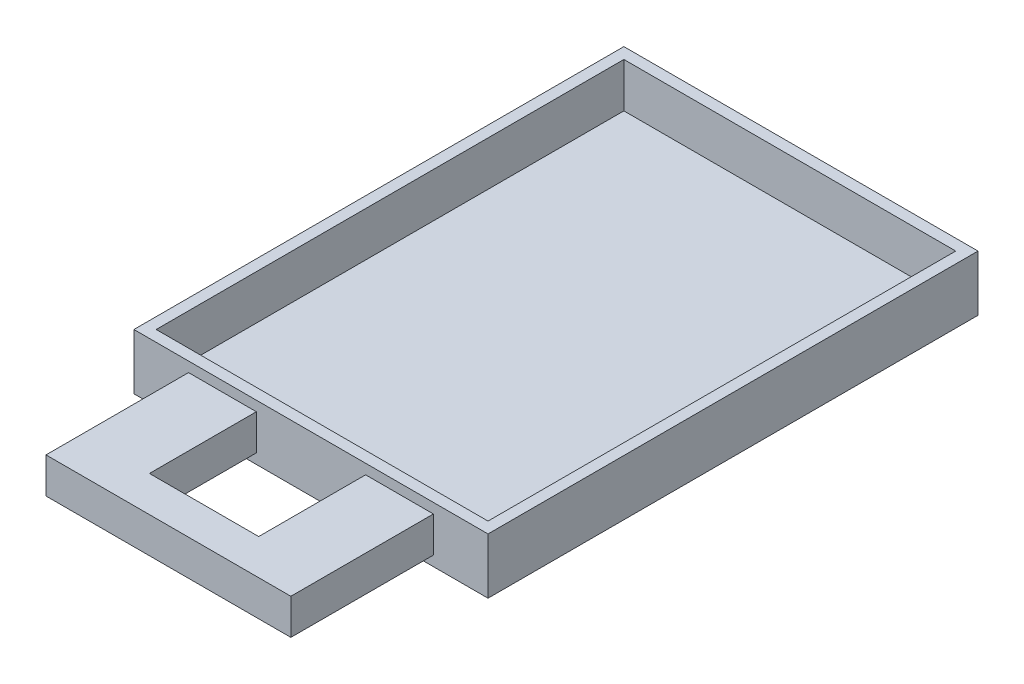
from build123d import *

# Parameters (mm, degrees)
SKETCH1_W           = 159
SKETCH1_H           = 25
BOSS_EXTRUDE1_DEPTH = 220
SKETCH2_W           = 149
SKETCH2_H           = 210
CUT_EXTRUDE1_DEPTH  = 20
SKETCH3_W           = 30.44
SKETCH3_H           = 16
BOSS_EXTRUDE2_DEPTH = 64
BOSS_EXTRUDE3_REACH = 305.485
SKETCH4_W           = 16
SKETCH4_H           = 16


with BuildPart() as part:
    # Sketch1 → Boss-Extrude1 (new body)
    with BuildSketch(Plane.XY):
        with Locations((0, 12.5)):
            Rectangle(SKETCH1_W, SKETCH1_H)
    extrude(amount=BOSS_EXTRUDE1_DEPTH)

    # Sketch2 → Cut-Extrude1 (cut)
    with BuildSketch(Plane(origin=(0, 25, 0), x_dir=(1, 0, 0), z_dir=(0, 1, 0))):
        with Locations((0, -110)):
            Rectangle(SKETCH2_W, SKETCH2_H)
    extrude(amount=-CUT_EXTRUDE1_DEPTH, mode=Mode.SUBTRACT)

    # Sketch3 → Boss-Extrude2 (add)
    with BuildSketch(Plane.XY.offset(220)):
        with Locations((-39.75, 12.5)):
            Rectangle(SKETCH3_W, SKETCH3_H)
    boss_extrude2 = extrude(amount=BOSS_EXTRUDE2_DEPTH)

    # Mirror1: Boss-Extrude2 across plane
    add(boss_extrude2.mirror(Plane(origin=(0, 0, 0), x_dir=(0, 0, 1), z_dir=(1, 0, 0))))

    # Sketch4 → Boss-Extrude3 (add, up to next)
    with BuildSketch(Plane(origin=(-24.53, 0, 0), x_dir=(0, 0, -1), z_dir=(1, 0, 0)), mode=Mode.PRIVATE) as boss_extrude3_sk1:
        with Locations((-276, 12.5)):
            Rectangle(SKETCH4_W, SKETCH4_H)
    boss_extrude3_tool1 = extrude(boss_extrude3_sk1.sketch, amount=BOSS_EXTRUDE3_REACH, mode=Mode.PRIVATE) - part.part
    add(boss_extrude3_tool1.solids().sort_by_distance((-24.53, 12.5, 276))[0])


solid = part.part
